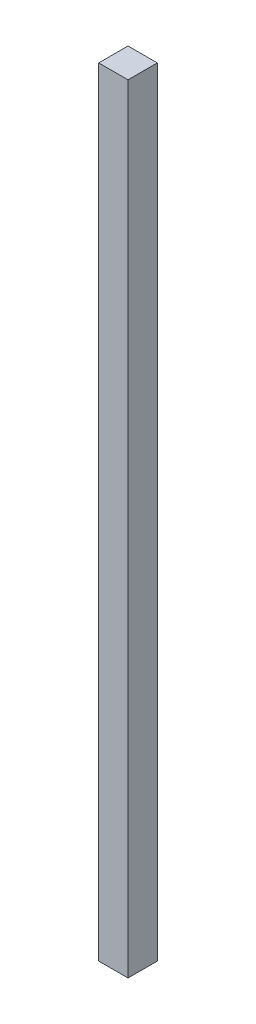
from build123d import *

# Parameters (mm, degrees)
SKETCH1_W           = 3.2
SKETCH1_H           = 3.2
BOSS_EXTRUDE1_DEPTH = 85


with BuildPart() as part:
    # Sketch1 → Boss-Extrude1 (new body)
    with BuildSketch(Plane(origin=(0, 0, 0), x_dir=(1, 0, 0), z_dir=(0, 1, 0))):
        with Locations((1.6, 1.6)):
            Rectangle(SKETCH1_W, SKETCH1_H)
    extrude(amount=BOSS_EXTRUDE1_DEPTH)


solid = part.part
